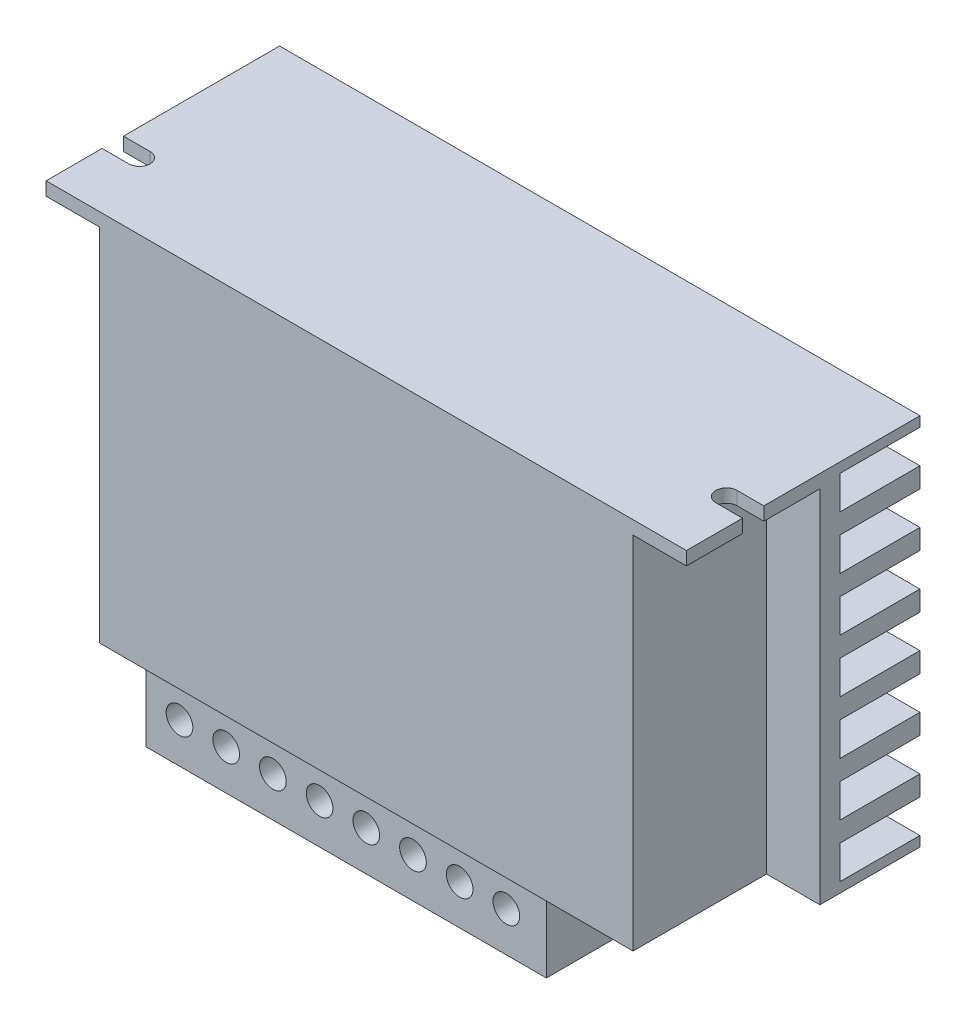
from build123d import *

# Parameters (mm, degrees)
SKETCH_1_W          = 96
SKETCH_1_H          = 56
EXTRUDE_1_DEPTH     = 35
SKETCH_5_W          = 20
SKETCH_5_H          = 54
CUT_EXTRUDE_3_DEPTH = 8
SKETCH_6_W          = 20
SKETCH_6_H          = 54
CUT_EXTRUDE_4_DEPTH = 8
SKETCH_7_W          = 12
SKETCH_7_H          = 5
CUT_EXTRUDE_5_DEPTH = 97
CUT_EXTRUDE_7_DEPTH = 3
SKETCH_9_W          = 60
SKETCH_9_H          = 15
EXTRUDE_2_DEPTH     = 12
SKETCH_10_R         = 2
CUT_EXTRUDE_8_DEPTH = 3
SKETCH_11_R         = 2.25
CUT_EXTRUDE_9_DEPTH = 15


with BuildPart() as part:
    # Эскиз1 → Бобышка-Вытянуть1 (new body)
    with BuildSketch(Plane.XY):
        with Locations((48, 28)):
            Rectangle(SKETCH_1_W, SKETCH_1_H)
    extrude(amount=EXTRUDE_1_DEPTH)

    # Эскиз5 → Вырез-Вытянуть3 (cut)
    with BuildSketch(Plane(origin=(96, 0, 0), x_dir=(0, 0, -1), z_dir=(1, 0, 0))):
        with Locations((-25, 27)):
            Rectangle(SKETCH_5_W, SKETCH_5_H)
    extrude(amount=-CUT_EXTRUDE_3_DEPTH, mode=Mode.SUBTRACT)

    # Эскиз6 → Вырез-Вытянуть4 (cut)
    with BuildSketch(Plane.ZY):
        with Locations((25, 27)):
            Rectangle(SKETCH_6_W, SKETCH_6_H)
    extrude(amount=-CUT_EXTRUDE_4_DEPTH, mode=Mode.SUBTRACT)

    # Эскиз7 → Вырез-Вытянуть5 (cut, through all)
    with BuildSketch(Plane(origin=(96, 0, 0), x_dir=(0, 0, -1), z_dir=(1, 0, 0))):
        with Locations((-6, 4)):
            Rectangle(SKETCH_7_W, SKETCH_7_H)
        with Locations((-6, 12)):
            Rectangle(SKETCH_7_W, SKETCH_7_H)
        with Locations((-6, 20)):
            Rectangle(SKETCH_7_W, SKETCH_7_H)
        with Locations((-6, 28)):
            Rectangle(SKETCH_7_W, SKETCH_7_H)
        with Locations((-6, 36)):
            Rectangle(SKETCH_7_W, SKETCH_7_H)
        with Locations((-6, 44)):
            Rectangle(SKETCH_7_W, SKETCH_7_H)
        with Locations((-6, 52)):
            Rectangle(SKETCH_7_W, SKETCH_7_H)
    extrude(amount=-CUT_EXTRUDE_5_DEPTH, mode=Mode.SUBTRACT)

    # Эскиз8 → Вырез-Вытянуть7 (cut, through all)
    with BuildSketch(Plane.XZ.offset(-54)):
        with BuildLine():
            ThreePointArc((4, 26.6), (5.6, 25), (4, 23.4))
            Line((4, 23.4), (0, 23.4))
            Line((0, 23.4), (0, 26.6))
            Line((0, 26.6), (4, 26.6))
        make_face()
        with BuildLine():
            Line((96, 26.6), (92, 26.6))
            ThreePointArc((92, 26.6), (90.4, 25), (92, 23.4))
            Line((92, 23.4), (96, 23.4))
            Line((96, 23.4), (96, 26.6))
        make_face()
    extrude(amount=-CUT_EXTRUDE_7_DEPTH, mode=Mode.SUBTRACT)

    # Эскиз9 → Бобышка-Вытянуть2 (add)
    with BuildSketch(Plane.XZ):
        with Locations((43, 25.5)):
            Rectangle(SKETCH_9_W, SKETCH_9_H)
    extrude(amount=EXTRUDE_2_DEPTH)

    # Эскиз10 → Вырез-Вытянуть8 (cut)
    with BuildSketch(Plane.XY.offset(33)):
        with Locations((18, -6)):
            Circle(SKETCH_10_R)
        with Locations((25, -6)):
            Circle(SKETCH_10_R)
        with Locations((32, -6)):
            Circle(SKETCH_10_R)
        with Locations((39, -6)):
            Circle(SKETCH_10_R)
        with Locations((46, -6)):
            Circle(SKETCH_10_R)
        with Locations((53, -6)):
            Circle(SKETCH_10_R)
        with Locations((60, -6)):
            Circle(SKETCH_10_R)
        with Locations((67, -6)):
            Circle(SKETCH_10_R)
    extrude(amount=-CUT_EXTRUDE_8_DEPTH, mode=Mode.SUBTRACT)

    # Эскиз11 → Вырез-Вытянуть9 (cut)
    with BuildSketch(Plane(origin=(0, 0, 0), x_dir=(-1, 0, 0), z_dir=(0, 0, -1))):
        with Locations((-23, 13)):
            Circle(SKETCH_11_R)
        with Locations((-73, 13)):
            Circle(SKETCH_11_R)
    extrude(amount=-CUT_EXTRUDE_9_DEPTH, mode=Mode.SUBTRACT)


solid = part.part
